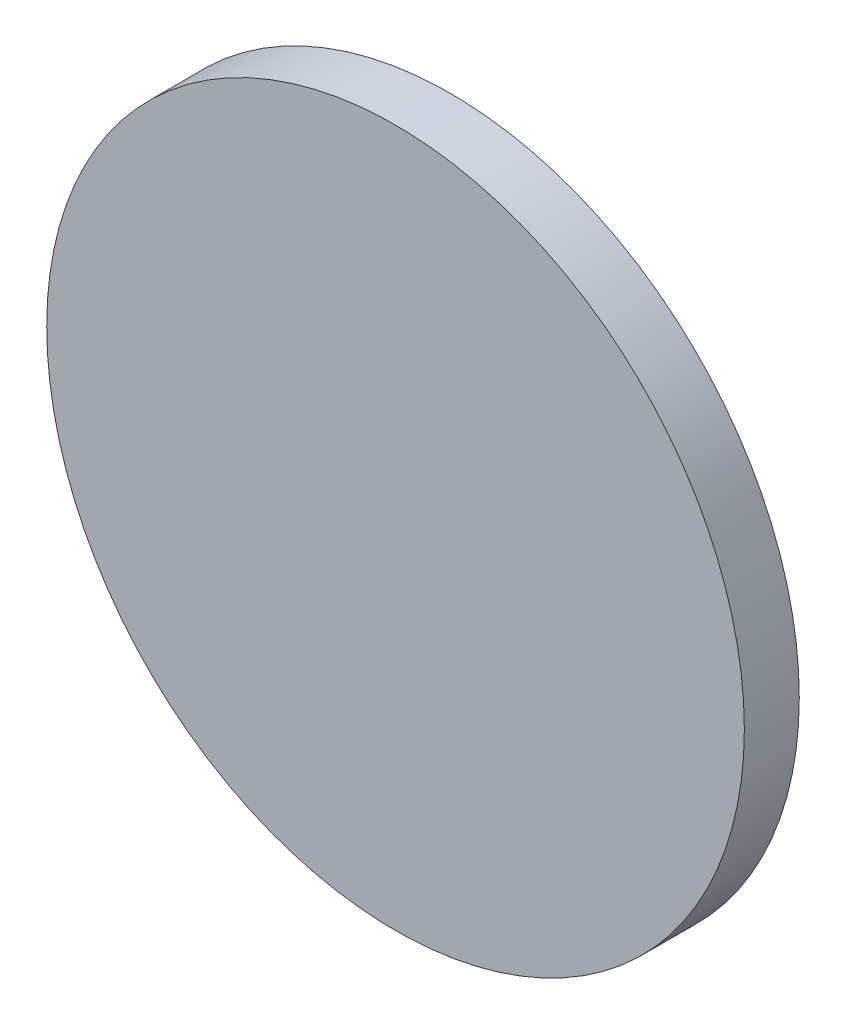
from build123d import *

# Parameters (mm, degrees)
SKETCH_1_R      = 12.7
EXTRUDE_1_DEPTH = 2


with BuildPart() as part:
    # 草图1 → 凸台-拉伸1 (new body)
    with BuildSketch(Plane.XY):
        Circle(SKETCH_1_R)
    extrude(amount=EXTRUDE_1_DEPTH)


solid = part.part
